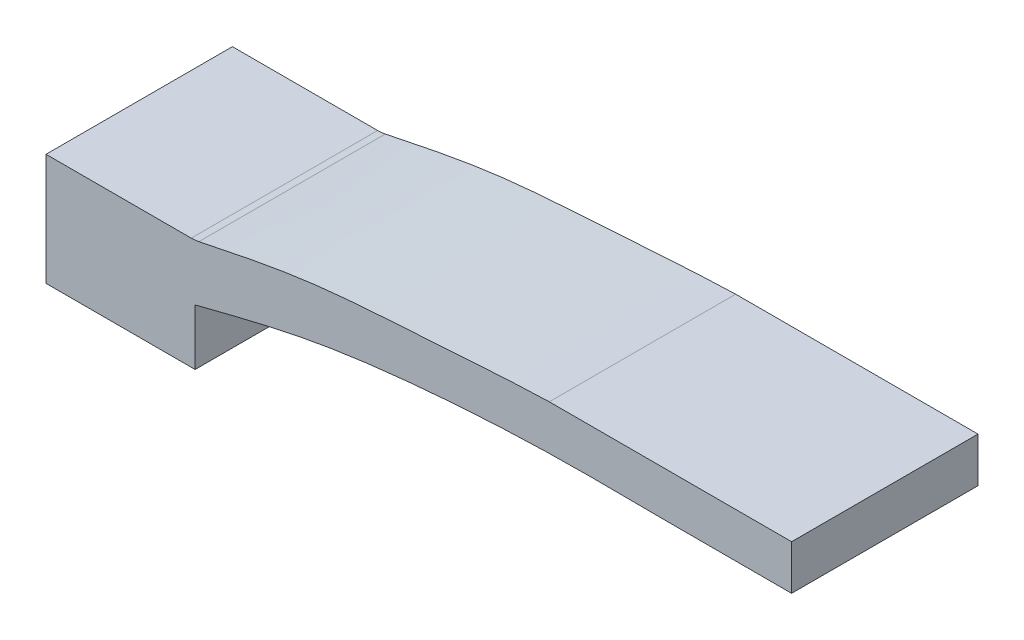
from build123d import *

# Parameters (mm, degrees)
SKETCH1_W           = 200
SKETCH1_H           = 50
BOSS_EXTRUDE1_DEPTH = 40
CUT_EXTRUDE1_DEPTH  = 51
CUT_EXTRUDE2_DEPTH  = 51.0000001
FILLET3_R           = 10


with BuildPart() as part:
    # Sketch1 → Boss-Extrude1 (new body)
    with BuildSketch(Plane(origin=(0, 0, 0), x_dir=(1, 0, 0), z_dir=(0, 1, 0))):
        with Locations((100, 25)):
            Rectangle(SKETCH1_W, SKETCH1_H)
    extrude(amount=BOSS_EXTRUDE1_DEPTH)

    # Sketch9 → Cut-Extrude1 (cut, through all)
    with BuildSketch(Plane.XY):
        with BuildLine():
            Line((40, 15), (40, 0))
            Line((40, 0), (200, 0))
            Line((200, 0), (200, 28))
            add(Edge.make_bspline(
                [(40, 15), (49.956623556, 17.554557146), (69.695225932, 22.618863079), (101.569485276, 26.484663085), (134.972625039, 28.43029981), (168.335074049, 27.910219147), (190.0005497, 27.971648152), (200, 28)],
                knots=[0, 0, 0, 0, 0.19118813, 0.379022714, 0.596595093, 0.81381312, 1, 1, 1, 1], degree=3))
        make_face()
    extrude(amount=-CUT_EXTRUDE1_DEPTH, mode=Mode.SUBTRACT)

    # Sketch11 → Cut-Extrude2 (cut, through all)
    with BuildSketch(Plane.XY):
        with BuildLine():
            Line((0, 30), (40, 30))
            add(Edge.make_bspline(
                [(40, 30), (49.965685719, 32.090607049), (69.767662187, 36.244676598), (101.665880925, 37.991623988), (123.327031089, 39.644618931), (135, 40)],
                knots=[0, 0, 0, 0, 0.233428343, 0.46382584, 0.73213141, 0.73213141, 0.73213141, 0.73213141], degree=3))
            Line((135, 40), (0, 40))
            Line((0, 40), (0, 30))
        make_face()
    extrude(amount=-CUT_EXTRUDE2_DEPTH, mode=Mode.SUBTRACT)

    # Fillet3
    fillet3_edges = [part.edges().sort_by_distance(p)[0] for p in [
        (40, 30, -25),
    ]]
    fillet(fillet3_edges, radius=FILLET3_R)


solid = part.part
